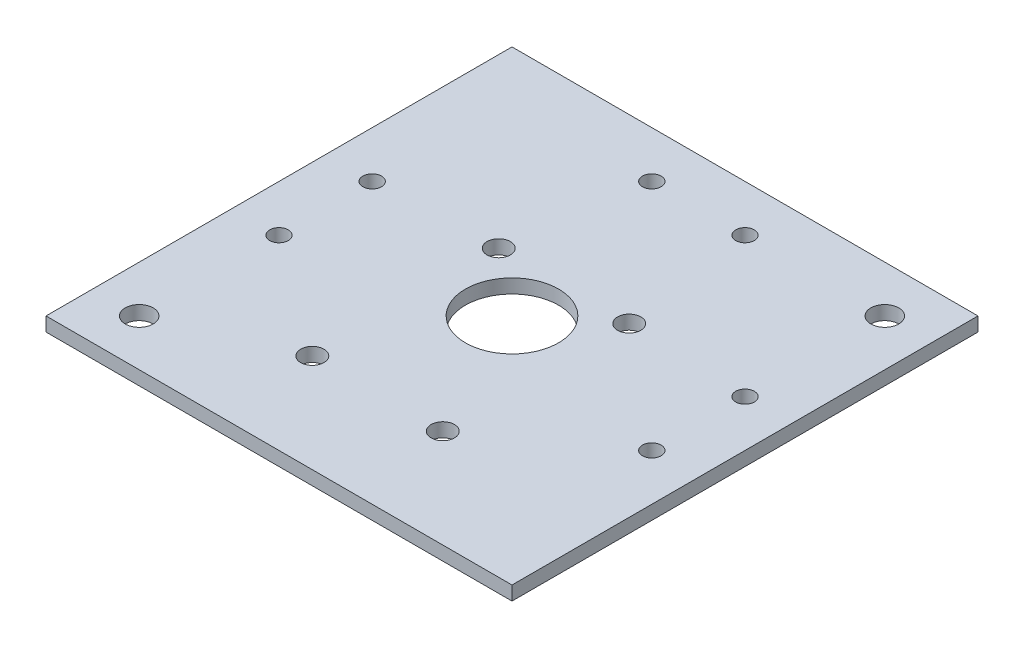
from build123d import *

# Parameters (mm, degrees)
SKETCH2_W               = 110
SKETCH2_H               = 110
SKETCH2_W_2             = 100
SKETCH2_H_2             = 100
BOSS_EXTRUDE1_DEPTH     = 89
SKETCH3_W               = 110
SKETCH3_H               = 110
BOSS_EXTRUDE2_DEPTH     = 8
CUT_EXTRUDE1_REACH      = 112
SKETCH6_W               = 60
SKETCH6_H               = 58
SKETCH9_W               = 110
SKETCH9_H               = 110
BOSS_EXTRUDE3_DEPTH     = 3
CUT_EXTRUDE2_REACH      = 63
SKETCH10_R              = 10
BOSS_EXTRUDE4_DEPTH     = 1.5
BOSS_EXTRUDE5_DEPTH     = 1.5
SKETCH14_R              = 3
CUT_EXTRUDE3_DEPTH      = 73
SKETCH15_W              = 2
SKETCH15_H              = 2
CUT_EXTRUDE4_DEPTH      = 113
CUT_EXTRUDE4_DEPTH_BACK = 13
CUT_EXTRUDE5_REACH      = 63
SKETCH16_R              = 2.5
SKETCH17_R              = 14
SKETCH17_R_2            = 11
BOSS_EXTRUDE6_DEPTH     = 7
CUT_EXTRUDE8_REACH      = 7
SKETCH20_R              = 2
SKETCH18_R              = 2
CUT_EXTRUDE6_DEPTH      = 73.5
CUT_EXTRUDE7_REACH      = 63
SKETCH19_R              = 2
SKETCH21_R              = 24
SKETCH21_R_2            = 21
BOSS_EXTRUDE7_DEPTH     = 5
SKETCH23_W              = 110
SKETCH23_H              = 110
CUT_EXTRUDE9_DEPTH      = 58
SKETCH24_W              = 110
SKETCH24_H              = 110
CUT_EXTRUDE10_DEPTH     = 34
CUT_EXTRUDE11_REACH     = 12
SKETCH25_W              = 110
SKETCH25_H              = 110
SKETCH25_W_2            = 100
SKETCH25_H_2            = 100
SKETCH26_R              = 14
CUT_EXTRUDE13_DEPTH     = 7


with BuildPart() as part:
    # Sketch2 → Boss-Extrude1 (new body)
    with BuildSketch(Plane(origin=(0, 0, 0), x_dir=(1, 0, 0), z_dir=(0, 1, 0))):
        Rectangle(SKETCH2_W, SKETCH2_H)
        Rectangle(SKETCH2_W_2, SKETCH2_H_2, mode=Mode.SUBTRACT)
    extrude(amount=BOSS_EXTRUDE1_DEPTH)

    # Sketch3 → Boss-Extrude2 (add)
    with BuildSketch(Plane(origin=(0, 89, 0), x_dir=(1, 0, 0), z_dir=(0, 1, 0))):
        Rectangle(SKETCH3_W, SKETCH3_H)
    extrude(amount=BOSS_EXTRUDE2_DEPTH)

    # Sketch6 → Cut-Extrude1 (cut, up to next)
    with BuildSketch(Plane.XY.offset(55), mode=Mode.PRIVATE) as cut_extrude1_sk1:
        with Locations((0, 29)):
            Rectangle(SKETCH6_W, SKETCH6_H)
    cut_extrude1_tool1 = extrude(cut_extrude1_sk1.sketch, amount=-CUT_EXTRUDE1_REACH, mode=Mode.PRIVATE) & part.part
    add(cut_extrude1_tool1.solids().sort_by_distance((0, 29, 55))[0], mode=Mode.SUBTRACT)

    # Sketch8 → Cut-Revolve1 (revolve, cut)
    with BuildSketch(Plane.XY):
        Polygon((0, 97), (-21, 97), (-21, 94.5), (-16.2, 94.5), (-16.2, 88.5), (0, 88.5), align=None)
    revolve(axis=Axis((0, 0, 0), (0, 1, 0)), mode=Mode.SUBTRACT)

    # Sketch9 → Boss-Extrude3 (add)
    with BuildSketch(Plane.XZ.offset(-58)):
        Rectangle(SKETCH9_W, SKETCH9_H)
    extrude(amount=-BOSS_EXTRUDE3_DEPTH)

    # Sketch10 → Cut-Extrude2 (cut, up to next)
    with BuildSketch(Plane(origin=(0, 61, 0), x_dir=(1, 0, 0), z_dir=(0, 1, 0)), mode=Mode.PRIVATE) as cut_extrude2_sk1:
        Circle(SKETCH10_R)
    cut_extrude2_tool1 = extrude(cut_extrude2_sk1.sketch, amount=-CUT_EXTRUDE2_REACH, mode=Mode.PRIVATE) & part.part
    add(cut_extrude2_tool1.solids().sort_by_distance((0, 61, 0))[0], mode=Mode.SUBTRACT)

    # Sketch11 → Boss-Extrude4 (add, symmetric)
    with BuildSketch(Plane.XY):
        Polygon((-50, 89), (-35, 89), (-50, 69), align=None)
    boss_extrude4 = extrude(amount=BOSS_EXTRUDE4_DEPTH, both=True)

    # Mirror1: Boss-Extrude4 across plane
    add(boss_extrude4.mirror(Plane(origin=(0, 0, 0), x_dir=(0, 0, 1), z_dir=(1, 0, 0))))

    # Sketch12 → Boss-Extrude5 (add, symmetric)
    with BuildSketch(Plane(origin=(0, 0, 0), x_dir=(0, 0, -1), z_dir=(1, 0, 0))):
        Polygon((-35, 89), (-50, 89), (-50, 69), align=None)
    boss_extrude5 = extrude(amount=BOSS_EXTRUDE5_DEPTH, both=True)

    # Mirror2: Boss-Extrude5 across plane
    add(boss_extrude5.mirror(Plane.XY))

    # Sketch14 → Cut-Extrude3 (cut)
    with BuildSketch(Plane(origin=(0, 97, 0), x_dir=(1, 0, 0), z_dir=(0, 1, 0))):
        with Locations((40, 40)):
            Circle(SKETCH14_R)
        with Locations((-40, -40)):
            Circle(SKETCH14_R)
    extrude(amount=-CUT_EXTRUDE3_DEPTH, mode=Mode.SUBTRACT)

    # Sketch15 → Cut-Extrude4 (cut, two sides)
    with BuildSketch(Plane(origin=(-50, 0, 0), x_dir=(0, 0, -1), z_dir=(1, 0, 0))) as cut_extrude4_sk:
        with Locations((-24, 62)):
            Rectangle(SKETCH15_W, SKETCH15_H)
        with Locations((24, 62)):
            Rectangle(SKETCH15_W, SKETCH15_H)
    extrude(amount=CUT_EXTRUDE4_DEPTH, mode=Mode.SUBTRACT)
    extrude(cut_extrude4_sk.sketch, amount=-CUT_EXTRUDE4_DEPTH_BACK, mode=Mode.SUBTRACT)

    # Sketch16 → Cut-Extrude5 (cut, up to next)
    with BuildSketch(Plane(origin=(0, 61, 0), x_dir=(1, 0, 0), z_dir=(0, 1, 0)), mode=Mode.PRIVATE) as cut_extrude5_sk1:
        with Locations((-14, 11.15)):
            Circle(SKETCH16_R)
    cut_extrude5_tool1 = extrude(cut_extrude5_sk1.sketch, amount=-CUT_EXTRUDE5_REACH, mode=Mode.PRIVATE) & part.part
    add(cut_extrude5_tool1.solids().sort_by_distance((-14, 61, -11.15))[0], mode=Mode.SUBTRACT)
    # Sketch16 → Cut-Extrude5 (cut, up to next)
    with BuildSketch(Plane(origin=(0, 61, 0), x_dir=(1, 0, 0), z_dir=(0, 1, 0)), mode=Mode.PRIVATE) as cut_extrude5_sk2:
        with Locations((-14, -28.85)):
            Circle(SKETCH16_R)
    cut_extrude5_tool2 = extrude(cut_extrude5_sk2.sketch, amount=-CUT_EXTRUDE5_REACH, mode=Mode.PRIVATE) & part.part
    add(cut_extrude5_tool2.solids().sort_by_distance((-14, 61, 28.85))[0], mode=Mode.SUBTRACT)
    # Sketch16 → Cut-Extrude5 (cut, up to next)
    with BuildSketch(Plane(origin=(0, 61, 0), x_dir=(1, 0, 0), z_dir=(0, 1, 0)), mode=Mode.PRIVATE) as cut_extrude5_sk3:
        with Locations((14, -28.85)):
            Circle(SKETCH16_R)
    cut_extrude5_tool3 = extrude(cut_extrude5_sk3.sketch, amount=-CUT_EXTRUDE5_REACH, mode=Mode.PRIVATE) & part.part
    add(cut_extrude5_tool3.solids().sort_by_distance((14, 61, 28.85))[0], mode=Mode.SUBTRACT)
    # Sketch16 → Cut-Extrude5 (cut, up to next)
    with BuildSketch(Plane(origin=(0, 61, 0), x_dir=(1, 0, 0), z_dir=(0, 1, 0)), mode=Mode.PRIVATE) as cut_extrude5_sk4:
        with Locations((14, 11.15)):
            Circle(SKETCH16_R)
    cut_extrude5_tool4 = extrude(cut_extrude5_sk4.sketch, amount=-CUT_EXTRUDE5_REACH, mode=Mode.PRIVATE) & part.part
    add(cut_extrude5_tool4.solids().sort_by_distance((14, 61, -11.15))[0], mode=Mode.SUBTRACT)

    # Sketch17 → Boss-Extrude6 (add)
    with BuildSketch(Plane(origin=(0, 61, 0), x_dir=(1, 0, 0), z_dir=(0, 1, 0))):
        Circle(SKETCH17_R)
        Circle(SKETCH17_R_2, mode=Mode.SUBTRACT)
    extrude(amount=BOSS_EXTRUDE6_DEPTH)

    # Sketch20 → Cut-Extrude8 (cut, up to next)
    with BuildSketch(Plane.XY.offset(-50), mode=Mode.PRIVATE) as cut_extrude8_sk1:
        with Locations((10, 48)):
            Circle(SKETCH20_R)
    cut_extrude8_tool1 = extrude(cut_extrude8_sk1.sketch, amount=-CUT_EXTRUDE8_REACH, mode=Mode.PRIVATE) & part.part
    add(cut_extrude8_tool1.solids().sort_by_distance((10, 48, -50))[0], mode=Mode.SUBTRACT)
    # Sketch20 → Cut-Extrude8 (cut, up to next)
    with BuildSketch(Plane.XY.offset(-50), mode=Mode.PRIVATE) as cut_extrude8_sk2:
        with Locations((-10, 48)):
            Circle(SKETCH20_R)
    cut_extrude8_tool2 = extrude(cut_extrude8_sk2.sketch, amount=-CUT_EXTRUDE8_REACH, mode=Mode.PRIVATE) & part.part
    add(cut_extrude8_tool2.solids().sort_by_distance((-10, 48, -50))[0], mode=Mode.SUBTRACT)

    # Sketch18 → Cut-Extrude6 (cut, symmetric)
    with BuildSketch(Plane(origin=(0, 0, 0), x_dir=(0, 0, -1), z_dir=(1, 0, 0))):
        with Locations((10, 48)):
            Circle(SKETCH18_R)
        with Locations((-10, 48)):
            Circle(SKETCH18_R)
    extrude(amount=CUT_EXTRUDE6_DEPTH, both=True, mode=Mode.SUBTRACT)

    # Sketch19 → Cut-Extrude7 (cut, up to next)
    with BuildSketch(Plane(origin=(0, 61, 0), x_dir=(1, 0, 0), z_dir=(0, 1, 0)), mode=Mode.PRIVATE) as cut_extrude7_sk1:
        with Locations((40, 10)):
            Circle(SKETCH19_R)
    cut_extrude7_tool1 = extrude(cut_extrude7_sk1.sketch, amount=-CUT_EXTRUDE7_REACH, mode=Mode.PRIVATE) & part.part
    add(cut_extrude7_tool1.solids().sort_by_distance((40, 61, -10))[0], mode=Mode.SUBTRACT)
    # Sketch19 → Cut-Extrude7 (cut, up to next)
    with BuildSketch(Plane(origin=(0, 61, 0), x_dir=(1, 0, 0), z_dir=(0, 1, 0)), mode=Mode.PRIVATE) as cut_extrude7_sk2:
        with Locations((40, -10)):
            Circle(SKETCH19_R)
    cut_extrude7_tool2 = extrude(cut_extrude7_sk2.sketch, amount=-CUT_EXTRUDE7_REACH, mode=Mode.PRIVATE) & part.part
    add(cut_extrude7_tool2.solids().sort_by_distance((40, 61, 10))[0], mode=Mode.SUBTRACT)
    # Sketch19 → Cut-Extrude7 (cut, up to next)
    with BuildSketch(Plane(origin=(0, 61, 0), x_dir=(1, 0, 0), z_dir=(0, 1, 0)), mode=Mode.PRIVATE) as cut_extrude7_sk3:
        with Locations((-40, -10)):
            Circle(SKETCH19_R)
    cut_extrude7_tool3 = extrude(cut_extrude7_sk3.sketch, amount=-CUT_EXTRUDE7_REACH, mode=Mode.PRIVATE) & part.part
    add(cut_extrude7_tool3.solids().sort_by_distance((-40, 61, 10))[0], mode=Mode.SUBTRACT)
    # Sketch19 → Cut-Extrude7 (cut, up to next)
    with BuildSketch(Plane(origin=(0, 61, 0), x_dir=(1, 0, 0), z_dir=(0, 1, 0)), mode=Mode.PRIVATE) as cut_extrude7_sk4:
        with Locations((-40, 10)):
            Circle(SKETCH19_R)
    cut_extrude7_tool4 = extrude(cut_extrude7_sk4.sketch, amount=-CUT_EXTRUDE7_REACH, mode=Mode.PRIVATE) & part.part
    add(cut_extrude7_tool4.solids().sort_by_distance((-40, 61, -10))[0], mode=Mode.SUBTRACT)
    # Sketch19 → Cut-Extrude7 (cut, up to next)
    with BuildSketch(Plane(origin=(0, 61, 0), x_dir=(1, 0, 0), z_dir=(0, 1, 0)), mode=Mode.PRIVATE) as cut_extrude7_sk5:
        with Locations((10, 40)):
            Circle(SKETCH19_R)
    cut_extrude7_tool5 = extrude(cut_extrude7_sk5.sketch, amount=-CUT_EXTRUDE7_REACH, mode=Mode.PRIVATE) & part.part
    add(cut_extrude7_tool5.solids().sort_by_distance((10, 61, -40))[0], mode=Mode.SUBTRACT)
    # Sketch19 → Cut-Extrude7 (cut, up to next)
    with BuildSketch(Plane(origin=(0, 61, 0), x_dir=(1, 0, 0), z_dir=(0, 1, 0)), mode=Mode.PRIVATE) as cut_extrude7_sk6:
        with Locations((-10, 40)):
            Circle(SKETCH19_R)
    cut_extrude7_tool6 = extrude(cut_extrude7_sk6.sketch, amount=-CUT_EXTRUDE7_REACH, mode=Mode.PRIVATE) & part.part
    add(cut_extrude7_tool6.solids().sort_by_distance((-10, 61, -40))[0], mode=Mode.SUBTRACT)

    # Sketch21 → Boss-Extrude7 (add)
    with BuildSketch(Plane(origin=(0, 97, 0), x_dir=(1, 0, 0), z_dir=(0, 1, 0))):
        Circle(SKETCH21_R)
        Circle(SKETCH21_R_2, mode=Mode.SUBTRACT)
    extrude(amount=BOSS_EXTRUDE7_DEPTH)

    # Sketch23 → Cut-Extrude9 (cut)
    with BuildSketch(Plane.XZ):
        Rectangle(SKETCH23_W, SKETCH23_H)
    extrude(amount=-CUT_EXTRUDE9_DEPTH, mode=Mode.SUBTRACT)

    # Sketch24 → Cut-Extrude10 (cut)
    with BuildSketch(Plane(origin=(0, 102, 0), x_dir=(1, 0, 0), z_dir=(0, 1, 0))):
        Rectangle(SKETCH24_W, SKETCH24_H)
    extrude(amount=-CUT_EXTRUDE10_DEPTH, mode=Mode.SUBTRACT)

    # Sketch25 → Cut-Extrude11 (cut, up to next)
    with BuildSketch(Plane(origin=(0, 68, 0), x_dir=(1, 0, 0), z_dir=(0, 1, 0)), mode=Mode.PRIVATE) as cut_extrude11_sk1:
        Rectangle(SKETCH25_W, SKETCH25_H)
        Rectangle(SKETCH25_W_2, SKETCH25_H_2, mode=Mode.SUBTRACT)
    cut_extrude11_tool1 = extrude(cut_extrude11_sk1.sketch, amount=-CUT_EXTRUDE11_REACH, mode=Mode.PRIVATE) & part.part
    add(cut_extrude11_tool1.solids().sort_by_distance((0, 68, 53.444365))[0], mode=Mode.SUBTRACT)

    # Sketch26 → Cut-Extrude13 (cut)
    with BuildSketch(Plane(origin=(0, 68, 0), x_dir=(1, 0, 0), z_dir=(0, 1, 0))):
        Circle(SKETCH26_R)
    extrude(amount=-CUT_EXTRUDE13_DEPTH, mode=Mode.SUBTRACT)


solid = part.part
